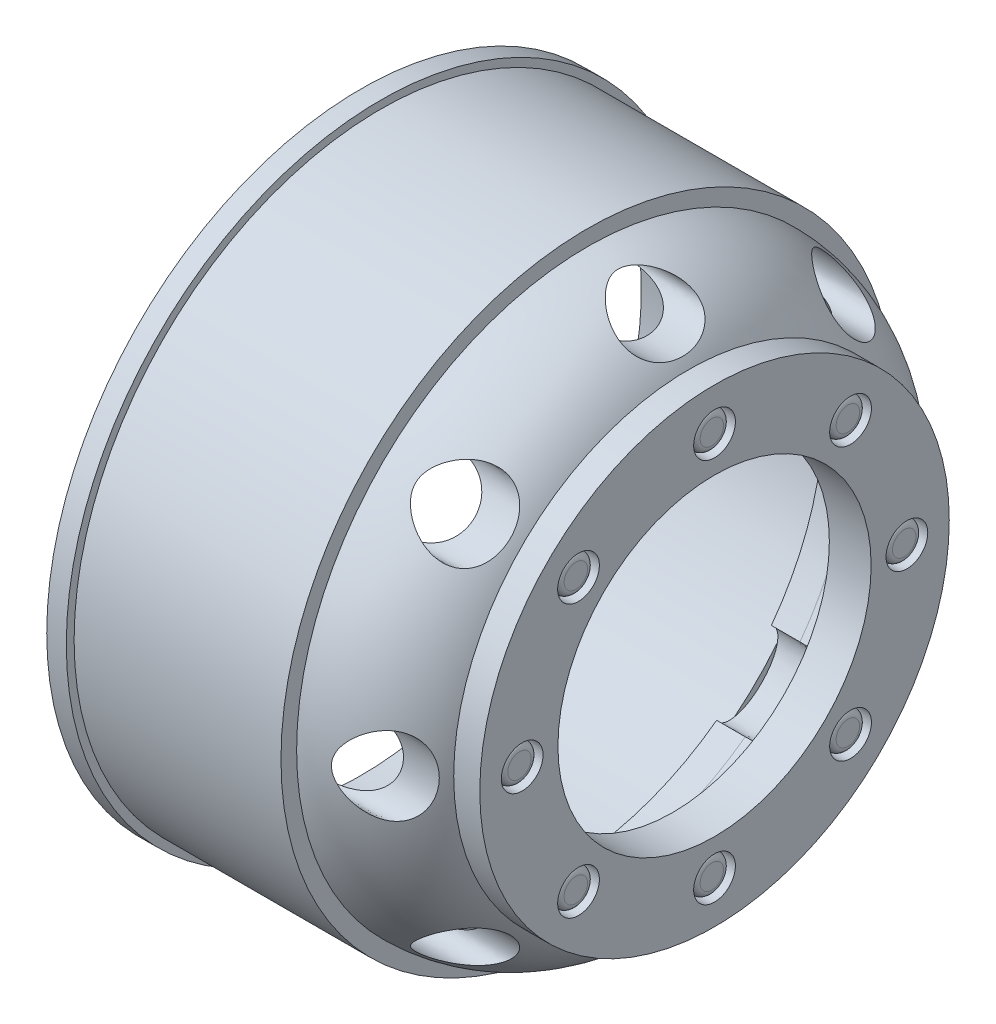
from build123d import *

# Parameters (mm, degrees)
SKETCH5_R           = 1.6
CUT_EXTRUDE3_DEPTH  = 1.703824
SKETCH6_R           = 1.4
BOSS_EXTRUDE1_DEPTH = 1.5
FILLET1_R           = 0.5
SKETCH7_R           = 12.008791447
CUT_EXTRUDE4_DEPTH  = 28.107079686
SKETCH3_RX          = 3
SKETCH3_RY          = 1.666666667
CUT_EXTRUDE5_DEPTH  = 11.939224
CIRPATTERN1_COUNT   = 8


with BuildPart() as part:
    # Sketch1 → Revolve1 (revolve)
    with BuildSketch(Plane.XY):
        with BuildLine():
            Line((-9.861268495, 23.5), (6, 23.5))
            Line((6, 23.5), (6, 22.3))
            ThreePointArc((6, 22.3), (10.429661133, 21.152912389), (13.745811191, 18))
            Line((13.745811191, 18), (15.745811191, 18))
            Line((15.745811191, 18), (15.745811191, 8.483712034))
            Line((15.745811191, 8.483712034), (12.541986778, 8.483712034))
            Line((12.541986778, 8.483712034), (12.541986778, 16))
            ThreePointArc((12.541986778, 16), (9.914319577, 19.128751492), (6, 20.3))
            Line((6, 20.3), (3.806587083, 20.3))
            Line((3.806587083, 20.3), (3.806587083, 21.5))
            Line((3.806587083, 21.5), (-9.861268495, 21.5))
            Line((-9.861268495, 21.5), (-10.271656636, 21.5))
            Line((-10.271656636, 21.5), (-11.361268495, 21.5))
            Line((-11.361268495, 21.5), (-11.361268495, 24.1))
            Line((-11.361268495, 24.1), (-9.861268495, 24.1))
            Line((-9.861268495, 24.1), (-9.861268495, 23.5))
        make_face()
    revolve(axis=Axis((-25, 0, 0), (1, 0, 0)))

    # Sketch5 → Cut-Extrude3 (cut)
    with BuildSketch(Plane(origin=(15.745811191, 0, 0), x_dir=(0, 0, -1), z_dir=(1, 0, 0))):
        with Locations((0, 14.75)):
            Circle(SKETCH5_R)
        with Locations((10.429825023, 10.429825023)):
            Circle(SKETCH5_R)
        with Locations((14.75, 0)):
            Circle(SKETCH5_R)
        with Locations((10.429825023, -10.429825023)):
            Circle(SKETCH5_R)
        with Locations((0, -14.75)):
            Circle(SKETCH5_R)
        with Locations((-10.429825023, -10.429825023)):
            Circle(SKETCH5_R)
        with Locations((-14.75, 0)):
            Circle(SKETCH5_R)
        with Locations((-10.429825023, 10.429825023)):
            Circle(SKETCH5_R)
    extrude(amount=-CUT_EXTRUDE3_DEPTH, mode=Mode.SUBTRACT)

    # Sketch6 → Boss-Extrude1 (add)
    with BuildSketch(Plane(origin=(14.041986778, 0, 0), x_dir=(0, 0, -1), z_dir=(1, 0, 0))):
        with Locations((-14.75, 0)):
            Circle(SKETCH6_R)
        with Locations((-10.429825023, 10.429825023)):
            Circle(SKETCH6_R)
        with Locations((0, 14.75)):
            Circle(SKETCH6_R)
        with Locations((10.429825023, 10.429825023)):
            Circle(SKETCH6_R)
        with Locations((14.75, 0)):
            Circle(SKETCH6_R)
        with Locations((10.429825023, -10.429825023)):
            Circle(SKETCH6_R)
        with Locations((0, -14.75)):
            Circle(SKETCH6_R)
        with Locations((-10.429825023, -10.429825023)):
            Circle(SKETCH6_R)
    extrude(amount=BOSS_EXTRUDE1_DEPTH)

    # Fillet1
    fillet1_edges = [part.edges().sort_by_distance(p)[0] for p in [
        (15.541986778, 0, 16.15),
        (15.541986778, 10.429825023, 11.829825023),
        (15.541986778, 14.75, 1.4),
        (15.541986778, 10.429825023, -9.029825023),
        (15.541986778, 0, -13.35),
        (15.541986778, -10.429825023, -9.029825023),
        (15.541986778, -14.75, 1.4),
        (15.541986778, -10.429825023, 11.829825023),
    ]]
    fillet(fillet1_edges, radius=FILLET1_R)

    # Sketch7 → Cut-Extrude4 (cut, through all)
    with BuildSketch(Plane(origin=(15.745811191, 0, 0), x_dir=(0, 0, -1), z_dir=(1, 0, 0))):
        Circle(SKETCH7_R)
    extrude(amount=-CUT_EXTRUDE4_DEPTH, mode=Mode.SUBTRACT)

    # Sketch3 → Cut-Extrude5 (cut)
    with BuildSketch(Plane(origin=(15.745811191, 0, 0), x_dir=(0, 0, -1), z_dir=(1, 0, 0))):
        with Locations((0, 20.323082194)):
            Ellipse(SKETCH3_RX, SKETCH3_RY)
    cut_extrude5 = extrude(amount=-CUT_EXTRUDE5_DEPTH, mode=Mode.SUBTRACT)

    # CirPattern1: Cut-Extrude5 ×8 about axis
    cirpattern1_axis = Axis((-25, 0, 0), (-1, 0, 0))
    for i in range(1, CIRPATTERN1_COUNT):
        add(cut_extrude5.rotate(cirpattern1_axis, i * 360 / CIRPATTERN1_COUNT), mode=Mode.SUBTRACT)


solid = part.part
